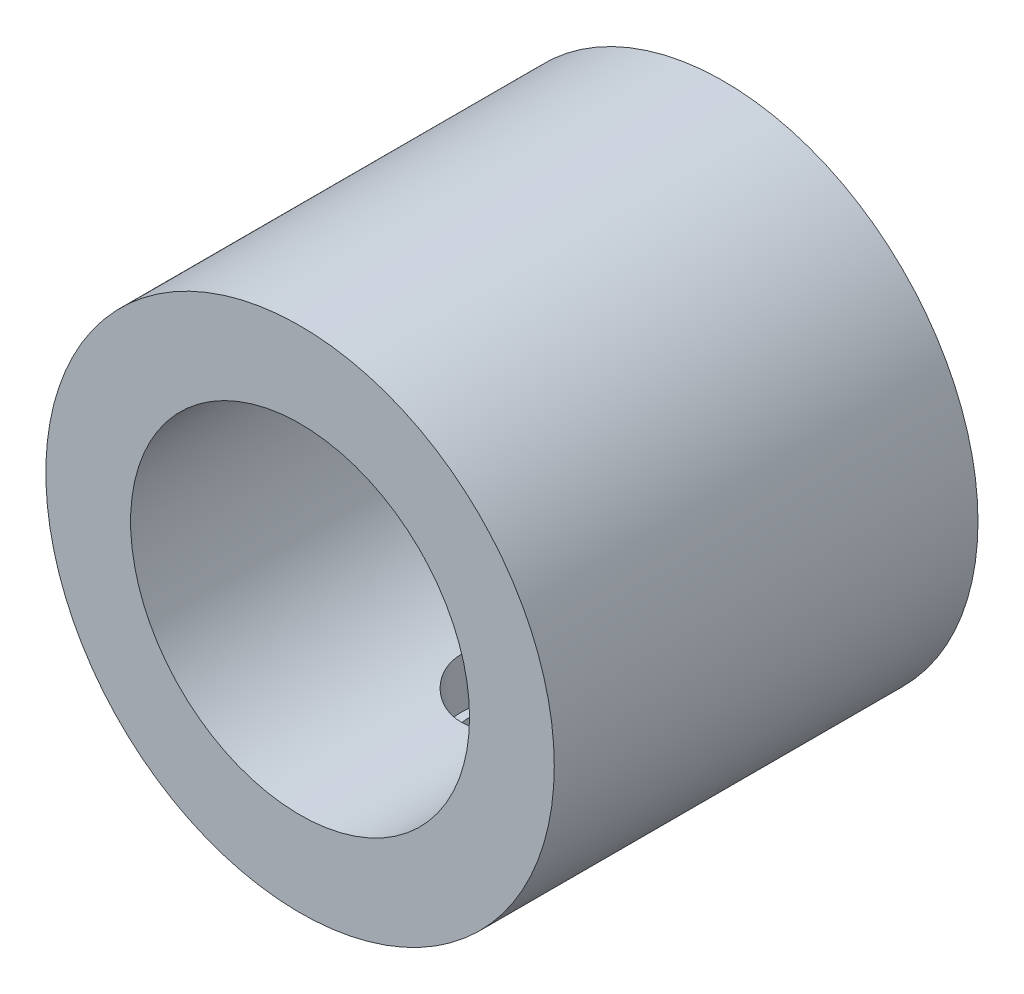
from build123d import *

# Parameters (mm, degrees)
SKETCH_1_R          = 3
SKETCH_1_R_2        = 2
EXTRUDE_1_DEPTH     = 5
SKETCH_2_R          = 0.5
CUT_EXTRUDE_1_DEPTH = 5
SKETCH_3_R          = 0.6
CUT_EXTRUDE_2_DEPTH = 2.5


with BuildPart() as part:
    # 草图1 → 凸台-拉伸1 (new body)
    with BuildSketch(Plane.XY):
        Circle(SKETCH_1_R)
        Circle(SKETCH_1_R_2, mode=Mode.SUBTRACT)
    extrude(amount=EXTRUDE_1_DEPTH)

    # 草图2 → 切除-拉伸1 (cut)
    with BuildSketch(Plane(origin=(0, 0, 0), x_dir=(1, 0, 0), z_dir=(0, 1, 0))):
        with Locations((0, -2.5)):
            Circle(SKETCH_2_R)
    extrude(amount=-CUT_EXTRUDE_1_DEPTH, mode=Mode.SUBTRACT)

    # 草图3 → 切除-拉伸2 (cut)
    with BuildSketch(Plane(origin=(0, 0, 0), x_dir=(1, 0, 0), z_dir=(0, 1, 0))):
        with Locations((0, -2.5)):
            Circle(SKETCH_3_R)
    extrude(amount=-CUT_EXTRUDE_2_DEPTH, mode=Mode.SUBTRACT)


solid = part.part
